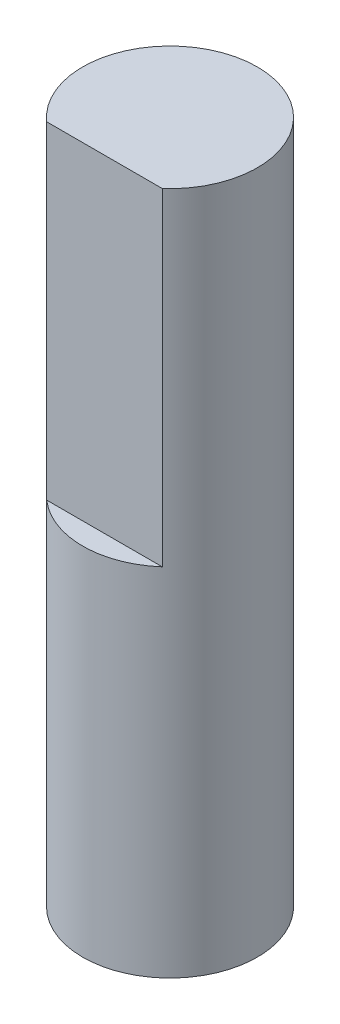
from build123d import *

# Parameters (mm, degrees)
SKETCH1_R           = 4
BOSS_EXTRUDE1_DEPTH = 31.3
CUT_EXTRUDE2_DEPTH  = 15


with BuildPart() as part:
    # Sketch1 → Boss-Extrude1 (new body)
    with BuildSketch(Plane(origin=(0, 0, 0), x_dir=(1, 0, 0), z_dir=(0, 1, 0))):
        Circle(SKETCH1_R)
    extrude(amount=BOSS_EXTRUDE1_DEPTH)

    # Sketch2 → Cut-Extrude2 (cut)
    with BuildSketch(Plane(origin=(0, 31.3, 0), x_dir=(1, 0, 0), z_dir=(0, 1, 0))):
        with BuildLine():
            Line((-2.645751311, -3), (2.645751311, -3))
            ThreePointArc((2.645751311, -3), (0, -4), (-2.645751311, -3))
        make_face()
    extrude(amount=-CUT_EXTRUDE2_DEPTH, mode=Mode.SUBTRACT)


solid = part.part
